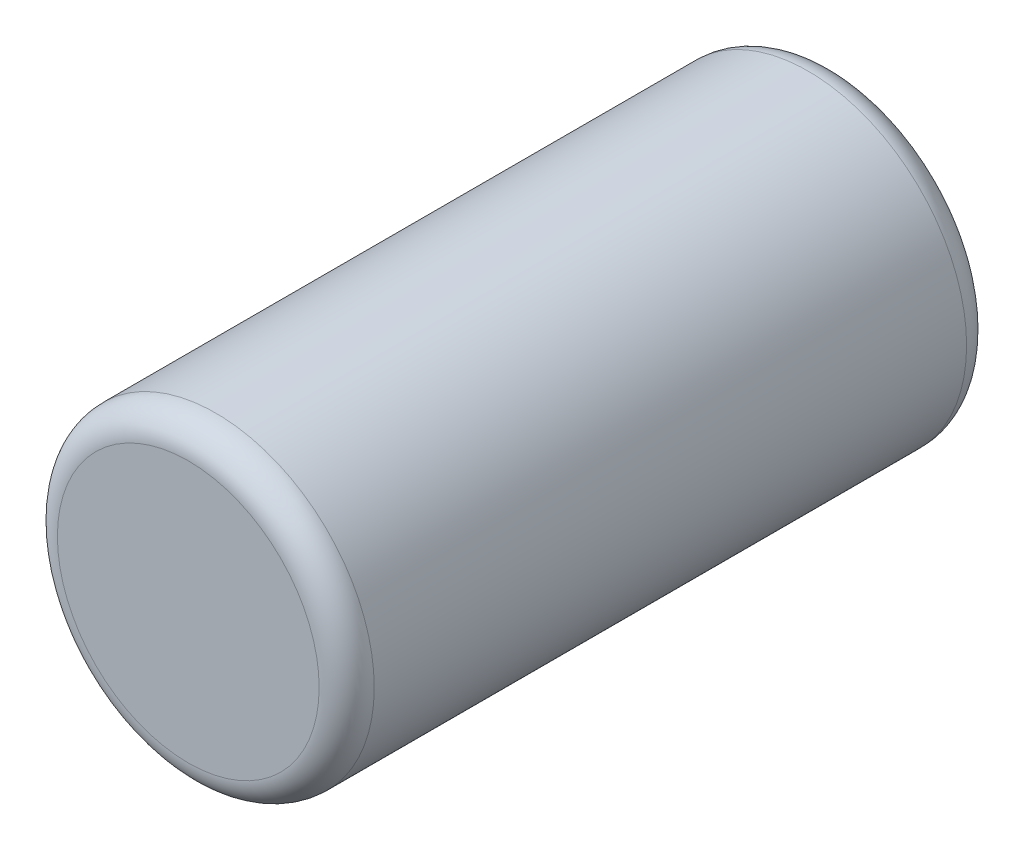
from build123d import *

# Parameters (mm, degrees)
ESQUISSE1_R        = 5.75
BOSS_EXTRU_1_DEPTH = 11.75
CONG_1_R           = 1


with BuildPart() as part:
    # Esquisse1 → Boss.-Extru.1 (new body, symmetric)
    with BuildSketch(Plane.XY):
        Circle(ESQUISSE1_R)
    extrude(amount=BOSS_EXTRU_1_DEPTH, both=True)

    # Congé1
    cong_1_edges = [part.edges().sort_by_distance(p)[0] for p in [
        (-5.75, 0, -11.75),
        (-5.75, 0, 11.75),
    ]]
    fillet(cong_1_edges, radius=CONG_1_R)


solid = part.part
